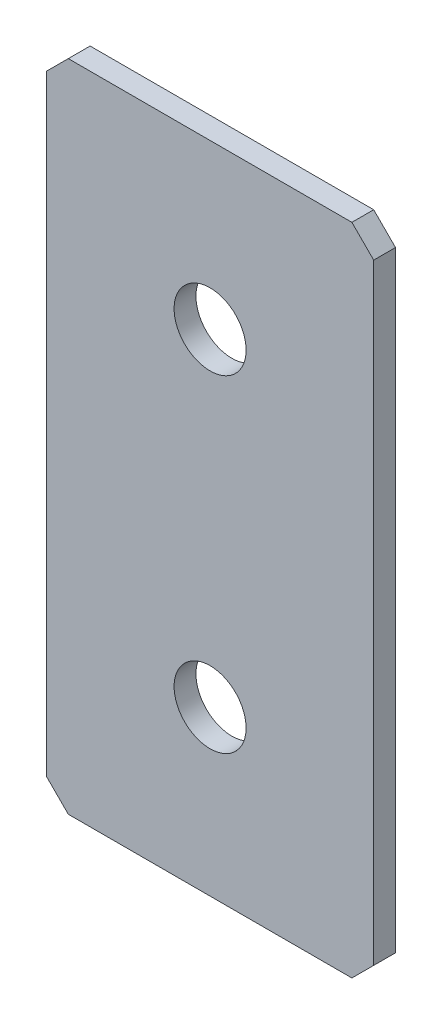
from build123d import *

# Parameters (mm, degrees)
SKETCH_1_W        = 30
SKETCH_1_H        = 60
EXTRUDE_1_DEPTH   = 2
CHAMFER_1_SIZE    = 2
HOLE_WIZARD_M61_D = 6.6


with BuildPart() as part:
    # Эскиз1 → Бобышка-Вытянуть1 (new body)
    with BuildSketch(Plane.XY):
        Rectangle(SKETCH_1_W, SKETCH_1_H)
    extrude(amount=EXTRUDE_1_DEPTH)

    # Фаска1
    chamfer_1_edges = [part.edges().sort_by_distance(p)[0] for p in [
        (15, -30, 1),
        (-15, -30, 1),
        (-15, 30, 1),
        (15, 30, 1),
    ]]
    chamfer(chamfer_1_edges, length=CHAMFER_1_SIZE)

    # Отверстие с зазором M61 (through all)
    with Locations(Plane.XY.offset(2)):
        with Locations((0, -45), (0, 45), (0, 15), (0, -15)):
            Hole(HOLE_WIZARD_M61_D / 2)


solid = part.part
